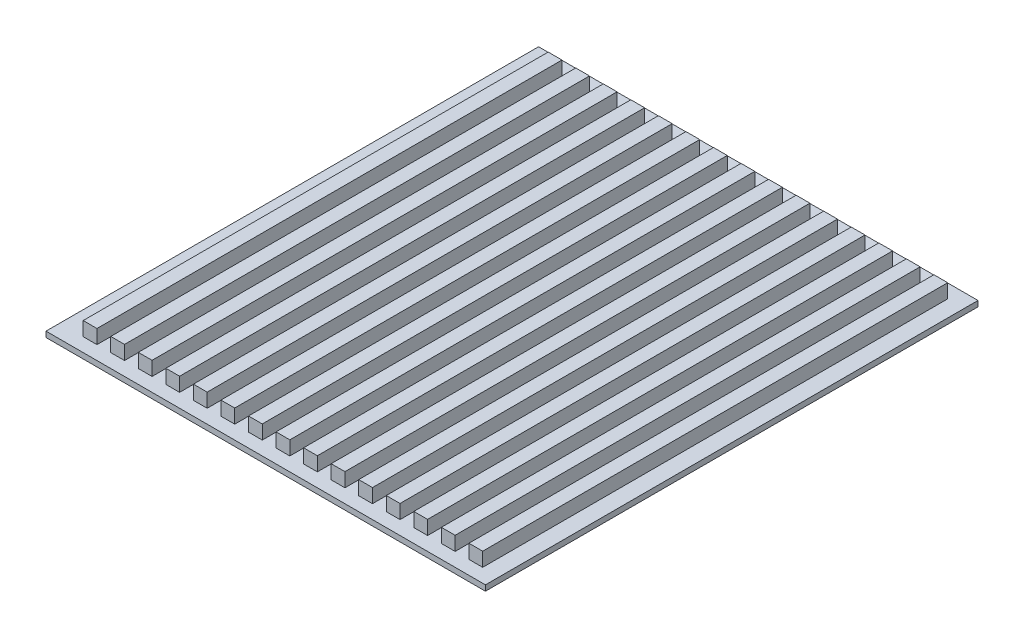
from build123d import *

# Parameters (mm, degrees)
SKETCH1_W                = 10
SKETCH1_H                = 14.198074023
BOSS_EXTRUDE1_DEPTH      = 337.560694
BOSS_EXTRUDE1_2_DEPTH    = 337.560694
BOSS_EXTRUDE1_3_DEPTH    = 337.560694
BOSS_EXTRUDE1_4_DEPTH    = 337.560694
BOSS_EXTRUDE1_5_DEPTH    = 337.560694
BOSS_EXTRUDE1_6_DEPTH    = 337.560694
BOSS_EXTRUDE1_7_DEPTH    = 337.560694
BOSS_EXTRUDE1_8_DEPTH    = 337.560694
BOSS_EXTRUDE1_9_DEPTH    = 337.560694
BOSS_EXTRUDE1_10_DEPTH   = 337.560694
BOSS_EXTRUDE1_11_DEPTH   = 337.560694
BOSS_EXTRUDE1_12_DEPTH   = 337.560694
BOSS_EXTRUDE1_13_DEPTH   = 337.560694
BOSS_EXTRUDE1_14_DEPTH   = 337.560694
BOSS_EXTRUDE1_15_DEPTH   = 337.560694
SKETCH2_W                = 290
SKETCH2_H                = 4.038074023
BOSS_EXTRUDE2_DEPTH      = 10
BOSS_EXTRUDE2_DEPTH_BACK = 10
SKETCH3_W                = 290
SKETCH3_H                = 4.038074023
BOSS_EXTRUDE3_DEPTH      = 10
BOSS_EXTRUDE3_DEPTH_BACK = 10
SKETCH4_W                = 357.560693512
SKETCH4_H                = 4.038074023
BOSS_EXTRUDE4_DEPTH      = 12
BOSS_EXTRUDE6_DEPTH      = 17


with BuildPart() as part:
    # Sketch1 → Boss-Extrude1 (new body)
    with BuildSketch(Plane.XY):
        with Locations((-5.671527203, 329.103441202)):
            Rectangle(SKETCH1_W, SKETCH1_H)
    extrude(amount=BOSS_EXTRUDE1_DEPTH)



with BuildPart() as body_2:
    # Sketch1 → Boss-Extrude1 2 (new body)
    with BuildSketch(Plane.XY):
        with Locations((-25.671527203, 329.103441202)):
            Rectangle(SKETCH1_W, SKETCH1_H)
    extrude(amount=BOSS_EXTRUDE1_2_DEPTH)


with BuildPart() as body_3:
    # Sketch1 → Boss-Extrude1 3 (new body)
    with BuildSketch(Plane.XY):
        with Locations((-45.671527203, 329.103441202)):
            Rectangle(SKETCH1_W, SKETCH1_H)
    extrude(amount=BOSS_EXTRUDE1_3_DEPTH)


with BuildPart() as body_4:
    # Sketch1 → Boss-Extrude1 4 (new body)
    with BuildSketch(Plane.XY):
        with Locations((-65.671527203, 329.103441202)):
            Rectangle(SKETCH1_W, SKETCH1_H)
    extrude(amount=BOSS_EXTRUDE1_4_DEPTH)


with BuildPart() as body_5:
    # Sketch1 → Boss-Extrude1 5 (new body)
    with BuildSketch(Plane.XY):
        with Locations((-85.671527203, 329.103441202)):
            Rectangle(SKETCH1_W, SKETCH1_H)
    extrude(amount=BOSS_EXTRUDE1_5_DEPTH)


with BuildPart() as body_6:
    # Sketch1 → Boss-Extrude1 6 (new body)
    with BuildSketch(Plane.XY):
        with Locations((-105.671527203, 329.103441202)):
            Rectangle(SKETCH1_W, SKETCH1_H)
    extrude(amount=BOSS_EXTRUDE1_6_DEPTH)


with BuildPart() as body_7:
    # Sketch1 → Boss-Extrude1 7 (new body)
    with BuildSketch(Plane.XY):
        with Locations((-125.671527203, 329.103441202)):
            Rectangle(SKETCH1_W, SKETCH1_H)
    extrude(amount=BOSS_EXTRUDE1_7_DEPTH)


with BuildPart() as body_8:
    # Sketch1 → Boss-Extrude1 8 (new body)
    with BuildSketch(Plane.XY):
        with Locations((-145.671527203, 329.103441202)):
            Rectangle(SKETCH1_W, SKETCH1_H)
    extrude(amount=BOSS_EXTRUDE1_8_DEPTH)


with BuildPart() as body_9:
    # Sketch1 → Boss-Extrude1 9 (new body)
    with BuildSketch(Plane.XY):
        with Locations((-165.671527203, 329.103441202)):
            Rectangle(SKETCH1_W, SKETCH1_H)
    extrude(amount=BOSS_EXTRUDE1_9_DEPTH)


with BuildPart() as body_10:
    # Sketch1 → Boss-Extrude1 10 (new body)
    with BuildSketch(Plane.XY):
        with Locations((-185.671527203, 329.103441202)):
            Rectangle(SKETCH1_W, SKETCH1_H)
    extrude(amount=BOSS_EXTRUDE1_10_DEPTH)


with BuildPart() as body_11:
    # Sketch1 → Boss-Extrude1 11 (new body)
    with BuildSketch(Plane.XY):
        with Locations((-205.671527203, 329.103441202)):
            Rectangle(SKETCH1_W, SKETCH1_H)
    extrude(amount=BOSS_EXTRUDE1_11_DEPTH)


with BuildPart() as body_12:
    # Sketch1 → Boss-Extrude1 12 (new body)
    with BuildSketch(Plane.XY):
        with Locations((-225.671527203, 329.103441202)):
            Rectangle(SKETCH1_W, SKETCH1_H)
    extrude(amount=BOSS_EXTRUDE1_12_DEPTH)


with BuildPart() as body_13:
    # Sketch1 → Boss-Extrude1 13 (new body)
    with BuildSketch(Plane.XY):
        with Locations((-245.671527203, 329.103441202)):
            Rectangle(SKETCH1_W, SKETCH1_H)
    extrude(amount=BOSS_EXTRUDE1_13_DEPTH)


with BuildPart() as body_14:
    # Sketch1 → Boss-Extrude1 14 (new body)
    with BuildSketch(Plane.XY):
        with Locations((-265.671527203, 329.103441202)):
            Rectangle(SKETCH1_W, SKETCH1_H)
    extrude(amount=BOSS_EXTRUDE1_14_DEPTH)


with BuildPart() as body_15:
    # Sketch1 → Boss-Extrude1 15 (new body)
    with BuildSketch(Plane.XY):
        with Locations((-285.671527203, 329.103441202)):
            Rectangle(SKETCH1_W, SKETCH1_H)
    extrude(amount=BOSS_EXTRUDE1_15_DEPTH)


with BuildPart() as part_1:
    add(part.part)

    add(body_2.part)  # Boss-Extrude2 merges body 2

    add(body_3.part)  # Boss-Extrude2 merges body 3

    add(body_4.part)  # Boss-Extrude2 merges body 4

    add(body_5.part)  # Boss-Extrude2 merges body 5

    add(body_6.part)  # Boss-Extrude2 merges body 6

    add(body_7.part)  # Boss-Extrude2 merges body 7

    add(body_8.part)  # Boss-Extrude2 merges body 8

    add(body_9.part)  # Boss-Extrude2 merges body 9

    add(body_10.part)  # Boss-Extrude2 merges body 10

    add(body_11.part)  # Boss-Extrude2 merges body 11

    add(body_12.part)  # Boss-Extrude2 merges body 12

    add(body_13.part)  # Boss-Extrude2 merges body 13

    add(body_14.part)  # Boss-Extrude2 merges body 14

    add(body_15.part)  # Boss-Extrude2 merges body 15
    # Sketch2 → Boss-Extrude2 (add, two sides)
    with BuildSketch(Plane.XY.offset(337.560693512)) as boss_extrude2_sk:
        with Locations((-145.671527203, 324.023441203)):
            Rectangle(SKETCH2_W, SKETCH2_H)
    extrude(amount=BOSS_EXTRUDE2_DEPTH)
    extrude(boss_extrude2_sk.sketch, amount=-BOSS_EXTRUDE2_DEPTH_BACK)

    # Sketch3 → Boss-Extrude3 (add, two sides)
    with BuildSketch(Plane(origin=(0, 0, 0), x_dir=(-1, 0, 0), z_dir=(0, 0, -1))) as boss_extrude3_sk:
        with Locations((145.671527203, 324.023441203)):
            Rectangle(SKETCH3_W, SKETCH3_H)
    extrude(amount=BOSS_EXTRUDE3_DEPTH)
    extrude(boss_extrude3_sk.sketch, amount=-BOSS_EXTRUDE3_DEPTH_BACK)

    # Sketch4 → Boss-Extrude4 (add)
    with BuildSketch(Plane(origin=(-0.671527203, 0, 0), x_dir=(0, 0, -1), z_dir=(1, 0, 0))):
        with Locations((-168.780346756, 324.023441203)):
            Rectangle(SKETCH4_W, SKETCH4_H)
    extrude(amount=BOSS_EXTRUDE4_DEPTH)

    # Sketch5 → Boss-Extrude6 (add)
    with BuildSketch(Plane.ZY.offset(290.671527203)):
        Polygon((337.560693512, 326.042478214), (0, 326.042478214), (-10, 326.042478214), (-10, 322.004404191), (347.560693512, 322.004404191), (347.560693512, 326.042478214), align=None)
    extrude(amount=BOSS_EXTRUDE6_DEPTH)


solid = part_1.part
